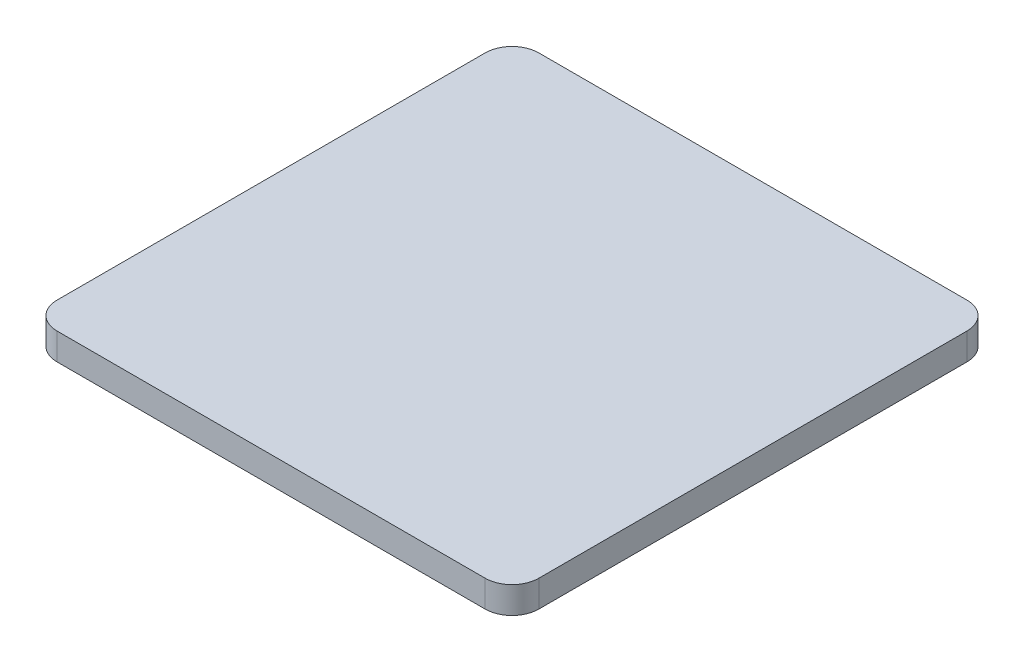
from build123d import *

# Parameters (mm, degrees)
RESSALTO_EXTRUS_O1_DEPTH = 10


with BuildPart() as part:
    # Esboço1 → Ressalto-extrusão1 (new body)
    with BuildSketch(Plane(origin=(0, 0, 0), x_dir=(1, 0, 0), z_dir=(0, 1, 0))):
        with BuildLine():
            Line((-80, -90), (80, -90))
            ThreePointArc((80, -90), (87.071067812, -87.071067812), (90, -80))
            Line((90, -80), (90, 80))
            ThreePointArc((90, 80), (87.071067812, 87.071067812), (80, 90))
            Line((80, 90), (-80, 90))
            ThreePointArc((-80, 90), (-87.071067812, 87.071067812), (-90, 80))
            Line((-90, 80), (-90, -80))
            ThreePointArc((-90, -80), (-87.071067812, -87.071067812), (-80, -90))
        make_face()
    extrude(amount=RESSALTO_EXTRUS_O1_DEPTH)


solid = part.part
